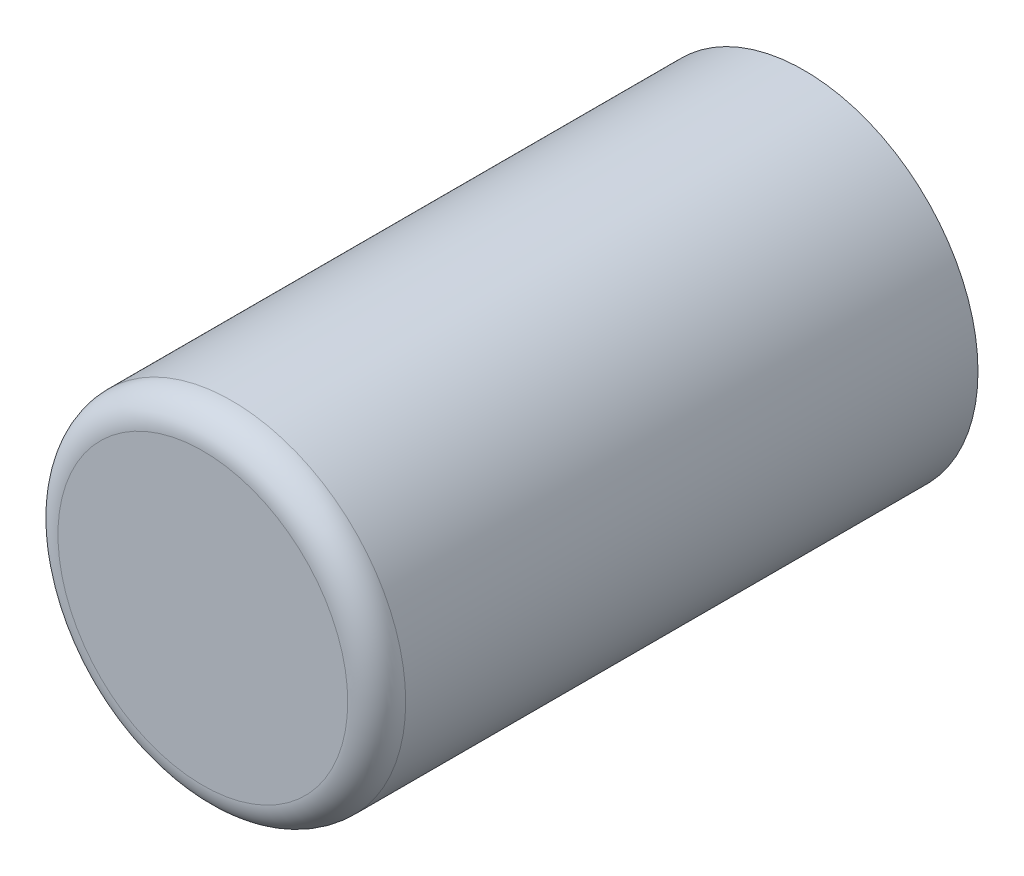
from build123d import *

# Parameters (mm, degrees)
SKETCH_1_R      = 24
EXTRUDE_1_DEPTH = 83
FILLET_1_R      = 4
SHELL_1_T       = -0.5


with BuildPart() as part:
    # ｽｹｯﾁ1 → ﾎﾞｽ - 押し出し1 (new body)
    with BuildSketch(Plane.XY):
        Circle(SKETCH_1_R)
    extrude(amount=EXTRUDE_1_DEPTH)

    # ﾌｨﾚｯﾄ1
    fillet_1_edges = [part.edges().sort_by_distance(p)[0] for p in [
        (-24, 0, 83),
    ]]
    fillet(fillet_1_edges, radius=FILLET_1_R)

    # ｼｪﾙ1
    shell_1_openings = [part.faces().sort_by_distance(p)[0] for p in [
        (0, 0, 0),
    ]]
    offset(amount=SHELL_1_T, openings=shell_1_openings, kind=Kind.INTERSECTION)


solid = part.part
